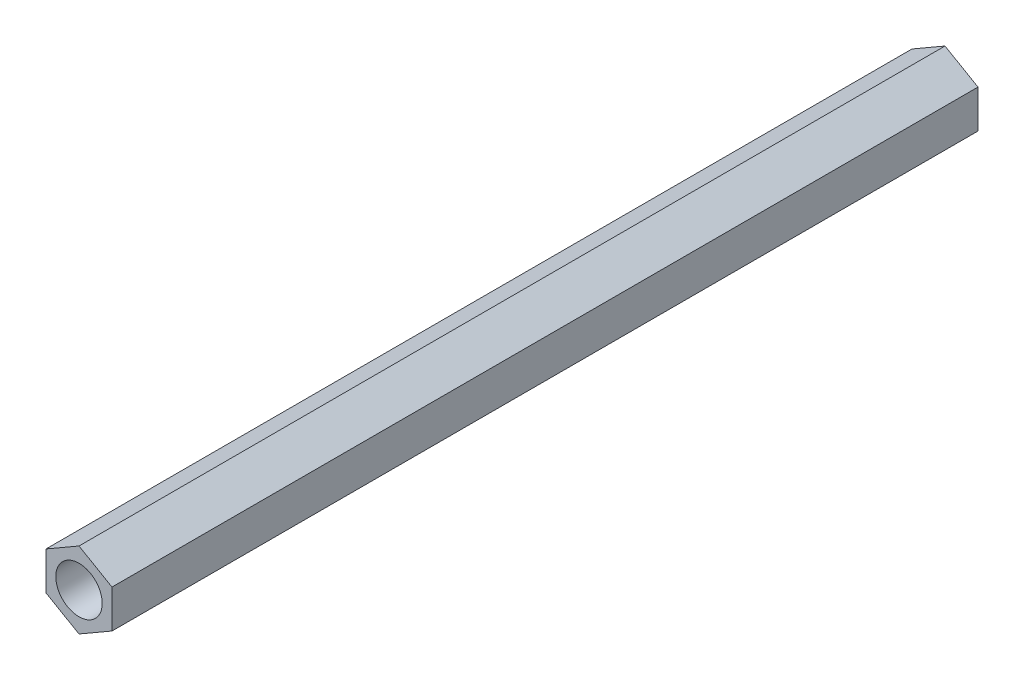
from build123d import *

# Parameters (mm, degrees)
SKETCH_1_R      = 1.5
EXTRUDE_1_DEPTH = 56


with BuildPart() as part:
    # 草图1 → 凸台-拉伸1 (new body)
    with BuildSketch(Plane.XY):
        Polygon((0, 2.463929225), (-2.133825302, 1.231964612), (-2.133825302, -1.231964612), (0, -2.463929225), (2.133825302, -1.231964612), (2.133825302, 1.231964612), align=None)
        Circle(SKETCH_1_R, mode=Mode.SUBTRACT)
    extrude(amount=EXTRUDE_1_DEPTH)


solid = part.part
